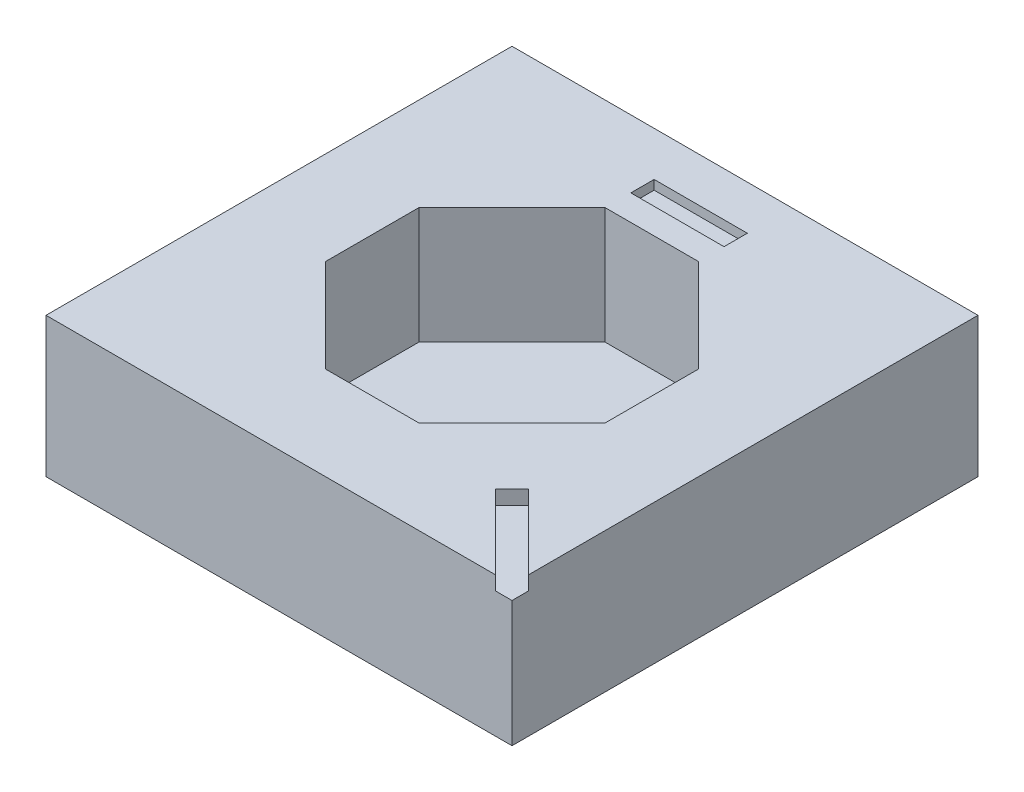
from build123d import *

# Parameters (mm, degrees)
SKETCH1_W                    = 100
SKETCH1_H                    = 100
BOSS_EXTRUDE1_DEPTH          = 30
CUT_EXTRUDE1_DEPTH           = 25
SKETCH3_W                    = 20
SKETCH3_H                    = 5
CUT_EXTRUDE_THIN1_DEPTH      = 2
CUT_EXTRUDE_THIN2_DEPTH      = 1
CUT_EXTRUDE_THIN2_DEPTH_BACK = 3


with BuildPart() as part:
    # Sketch1 → Boss-Extrude1 (new body)
    with BuildSketch(Plane(origin=(0, 0, 0), x_dir=(1, 0, 0), z_dir=(0, 1, 0))):
        Rectangle(SKETCH1_W, SKETCH1_H)
    extrude(amount=BOSS_EXTRUDE1_DEPTH)

    # Sketch2 → Cut-Extrude1 (cut)
    with BuildSketch(Plane(origin=(0, 30, 0), x_dir=(1, 0, 0), z_dir=(0, 1, 0))):
        Polygon((30, 10), (10, 30), (-10, 30), (-30, 10), (-30, -10), (-10, -30), (10, -30), (30, -10), align=None)
    extrude(amount=-CUT_EXTRUDE1_DEPTH, mode=Mode.SUBTRACT)

    # Sketch3 → Cut-Extrude-Thin1 (cut)
    with BuildSketch(Plane(origin=(0, 30, 0), x_dir=(1, 0, 0), z_dir=(0, 1, 0))):
        with Locations((0, 38)):
            Rectangle(SKETCH3_W, SKETCH3_H)
    extrude(amount=-CUT_EXTRUDE_THIN1_DEPTH, mode=Mode.SUBTRACT)

    # Sketch4 → Cut-Extrude-Thin2 (cut, two sides)
    with BuildSketch(Plane(origin=(0, 30, 0), x_dir=(1, 0, 0), z_dir=(0, 1, 0))) as cut_extrude_thin2_sk:
        Polygon((51.767766953, -48.232233047), (34.090097423, -30.554563517), (30.554563517, -34.090097423), (48.232233047, -51.767766953), align=None)
    extrude(amount=CUT_EXTRUDE_THIN2_DEPTH, mode=Mode.SUBTRACT)
    extrude(cut_extrude_thin2_sk.sketch, amount=-CUT_EXTRUDE_THIN2_DEPTH_BACK, mode=Mode.SUBTRACT)


solid = part.part
